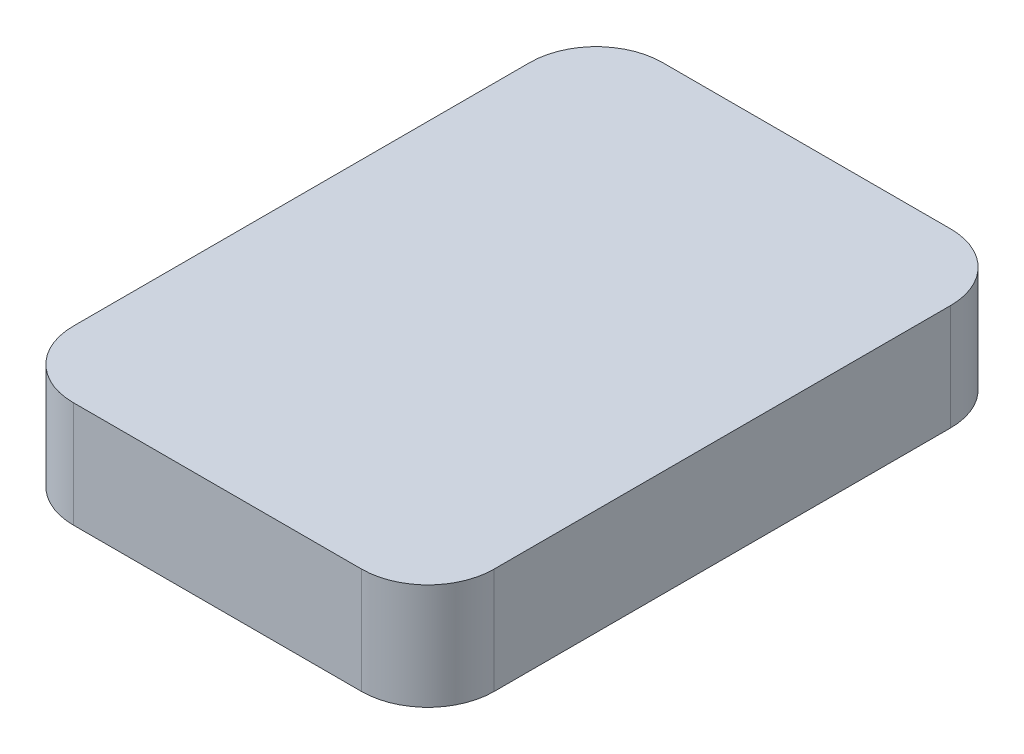
from build123d import *

# Parameters (mm, degrees)
SKETCH1_W           = 63.5
SKETCH1_H           = 88.9
BOSS_EXTRUDE1_DEPTH = 16
FILLET1_R           = 10


with BuildPart() as part:
    # Sketch1 → Boss-Extrude1 (new body)
    with BuildSketch(Plane(origin=(0, 0, 0), x_dir=(1, 0, 0), z_dir=(0, 1, 0))):
        Rectangle(SKETCH1_W, SKETCH1_H)
    extrude(amount=BOSS_EXTRUDE1_DEPTH)

    # Fillet1
    fillet1_edges = [part.edges().sort_by_distance(p)[0] for p in [
        (31.75, 8, 44.45),
        (-31.75, 8, 44.45),
        (-31.75, 8, -44.45),
        (31.75, 8, -44.45),
    ]]
    fillet(fillet1_edges, radius=FILLET1_R)


solid = part.part
